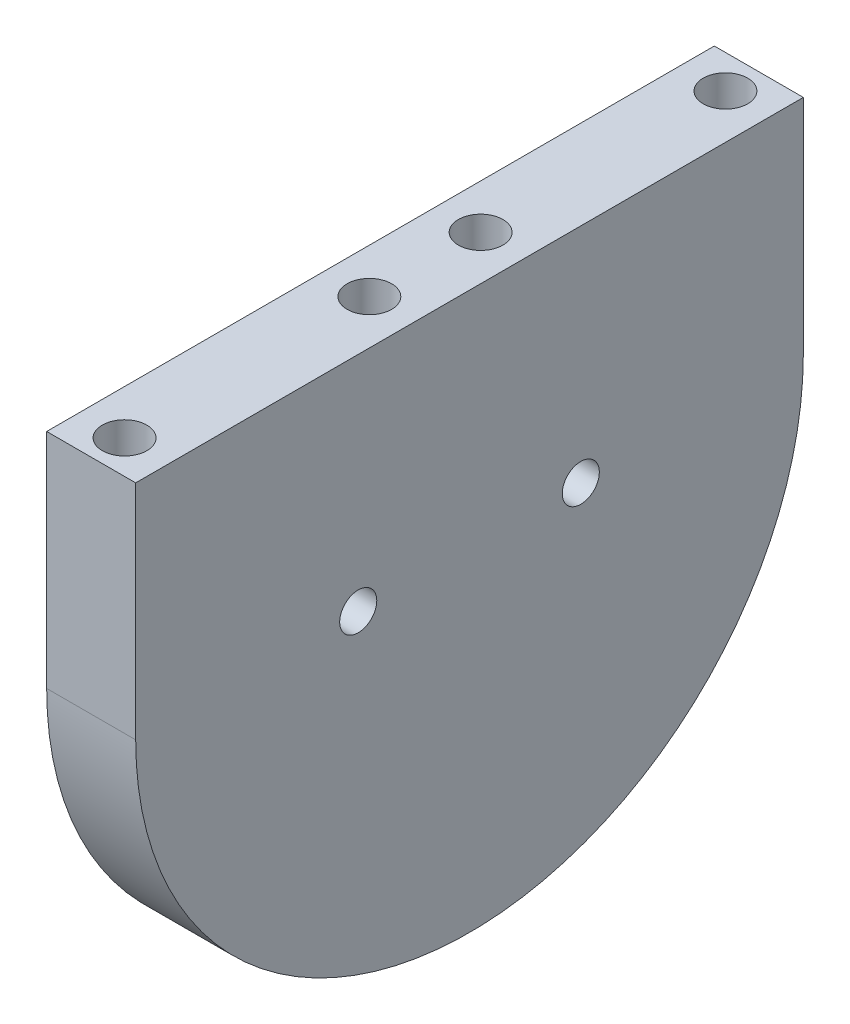
from build123d import *

# Parameters (mm, degrees)
SKETCH1_R           = 2.5
BOSS_EXTRUDE1_DEPTH = 12
SKETCH2_R           = 3
CUT_EXTRUDE1_DEPTH  = 25


with BuildPart() as part:
    # Sketch1 → Boss-Extrude1 (new body)
    with BuildSketch(Plane(origin=(0, 0, 0), x_dir=(0, 0, -1), z_dir=(1, 0, 0))):
        with BuildLine():
            Line((-45, 0), (-45, 30))
            Line((-45, 30), (45, 30))
            Line((45, 30), (45, 0))
            ThreePointArc((45, 0), (0, -45), (-45, 0))
        make_face()
        with Locations((-15, 0)):
            Circle(SKETCH1_R, mode=Mode.SUBTRACT)
        with Locations((15, 0)):
            Circle(SKETCH1_R, mode=Mode.SUBTRACT)
    extrude(amount=BOSS_EXTRUDE1_DEPTH)

    # Sketch2 → Cut-Extrude1 (cut)
    with BuildSketch(Plane(origin=(0, 30, 0), x_dir=(1, 0, 0), z_dir=(0, 1, 0))):
        with Locations((6, 40.5)):
            Circle(SKETCH2_R)
        with Locations((6, 7.5)):
            Circle(SKETCH2_R)
        with Locations((6, -7.5)):
            Circle(SKETCH2_R)
        with Locations((6, -40.5)):
            Circle(SKETCH2_R)
    extrude(amount=-CUT_EXTRUDE1_DEPTH, mode=Mode.SUBTRACT)


solid = part.part
